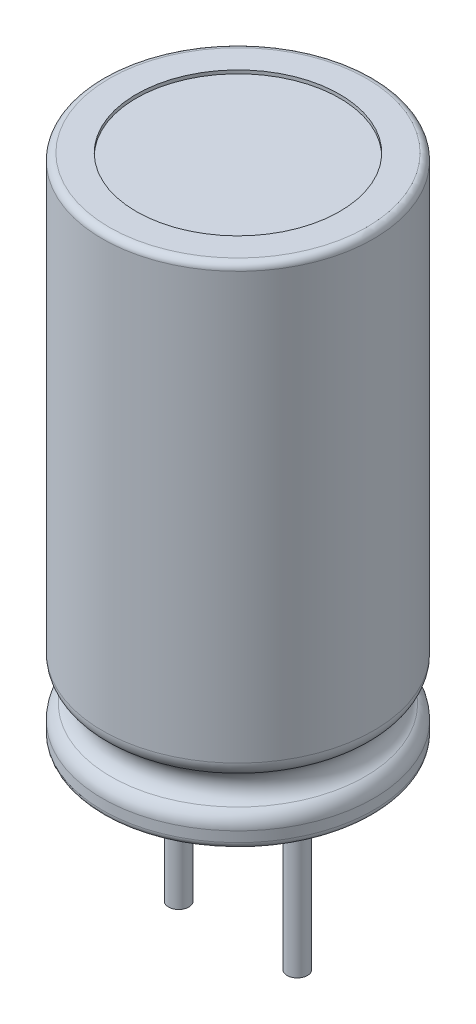
from build123d import *

# Parameters (mm, degrees)
FILLET2_R             = 0.2
SKETCH3_R             = 3
CUT_EXTRUDE1_DEPTH    = 0.1
SKETCH4_R             = 3
CUT_EXTRUDE2_DEPTH    = 0.1
SKETCH2_R             = 0.3
BOSS_EXTRUDE1_DEPTH   = 5
BOSS_EXTRUDE1_2_DEPTH = 5


with BuildPart() as part:
    # Sketch1 → Revolve1 (revolve)
    with BuildSketch(Plane.XY):
        with BuildLine():
            Line((0, 0), (0, 15))
            Line((0, 15), (-4, 15))
            Line((-4, 15), (-4, 2.232050808))
            ThreePointArc((-4, 2.232050808), (-3.933012702, 1.982050808), (-3.75, 1.799038106))
            ThreePointArc((-3.75, 1.799038106), (-3.5, 1.366025404), (-3.75, 0.933012702))
            ThreePointArc((-3.75, 0.933012702), (-3.933012702, 0.75), (-4, 0.5))
            Line((-4, 0.5), (-4, 0))
            Line((-4, 0), (0, 0))
        make_face()
    revolve(axis=Axis((0, 0, 0), (0, 1, 0)))

    # Fillet2
    fillet2_edges = [part.edges().sort_by_distance(p)[0] for p in [
        (4, 0, 0),
        (4, 15, 0),
    ]]
    fillet(fillet2_edges, radius=FILLET2_R)

    # Sketch3 → Cut-Extrude1 (cut)
    with BuildSketch(Plane(origin=(0, 15, 0), x_dir=(1, 0, 0), z_dir=(0, 1, 0))):
        Circle(SKETCH3_R)
    extrude(amount=-CUT_EXTRUDE1_DEPTH, mode=Mode.SUBTRACT)

    # Sketch4 → Cut-Extrude2 (cut)
    with BuildSketch(Plane.XZ):
        Circle(SKETCH4_R)
    extrude(amount=-CUT_EXTRUDE2_DEPTH, mode=Mode.SUBTRACT)


with BuildPart() as body_2:
    # Sketch2 → Boss-Extrude1 (new body, symmetric)
    with BuildSketch(Plane.XZ):
        with Locations((-1.75, 0)):
            Circle(SKETCH2_R)
    extrude(amount=BOSS_EXTRUDE1_DEPTH, both=True)


with BuildPart() as body_3:
    # Sketch2 → Boss-Extrude1 2 (new body, symmetric)
    with BuildSketch(Plane.XZ):
        with Locations((1.75, 0)):
            Circle(SKETCH2_R)
    extrude(amount=BOSS_EXTRUDE1_2_DEPTH, both=True)


solid = Compound([part.part, body_2.part, body_3.part])
